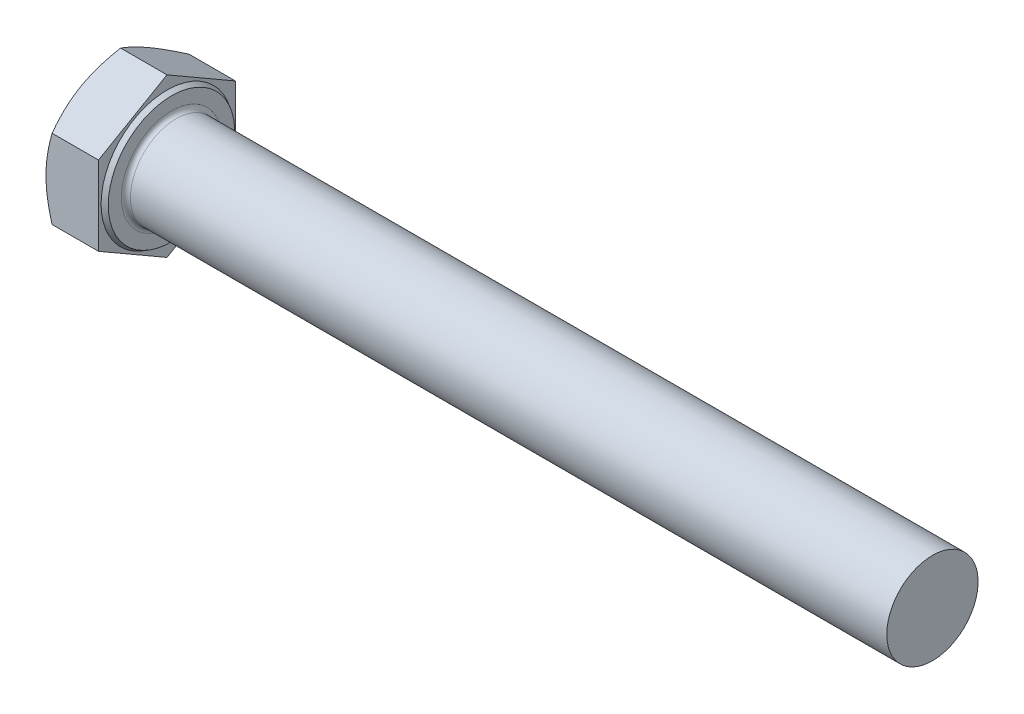
from build123d import *

# Parameters (mm, degrees)
EXTRUDE_382_DEPTH = 7.5
FILLET_1274_R     = 0.6


with BuildPart() as part:
    # 草图1 → Extrude 382 (new body)
    with BuildSketch(Plane(origin=(0, 0, 0), x_dir=(0, 0, -1), z_dir=(1, 0, 0))):
        Polygon((9, 5.196152423), (9, -5.196152423), (0, -10.392304845), (-9, -5.196152423), (-9, 5.196152423), (0, 10.392304845), align=None)
    extrude(amount=EXTRUDE_382_DEPTH)

    # 草图2 → 凸台-旋转1 (revolve)
    with BuildSketch(Plane.XY):
        Polygon((0, 0), (107.5, 0), (107.5, 4.4845), (107.5, 6), (77.5, 6), (0, 6), align=None)
    revolve(axis=Axis((0, 0, 0), (1, 0, 0)))

    # 草图3 → 切除-旋转1 (revolve, cut)
    with BuildSketch(Plane.XY):
        Polygon((0, 9), (3.690598923, 15.392304845), (3.690598923, 20.392304845), (-10, 20.392304845), (-10, 9), align=None)
    revolve(axis=Axis((0, 0, 0), (1, 0, 0)), mode=Mode.SUBTRACT)

    # 草图4 → 切除-旋转3 (revolve, cut)
    with BuildSketch(Plane.XY):
        Polygon((7.5, 8.315), (6.9, 8.661410162), (6.9, 10.392304845), (7.5, 10.392304845), align=None)
    revolve(axis=Axis((0, 0, 0), (1, 0, 0)), mode=Mode.SUBTRACT)

    # Fillet 1274
    fillet_1274_edges = [part.edges().sort_by_distance(p)[0] for p in [
        (7.5, -6, 0),
    ]]
    fillet(fillet_1274_edges, radius=FILLET_1274_R)


solid = part.part
